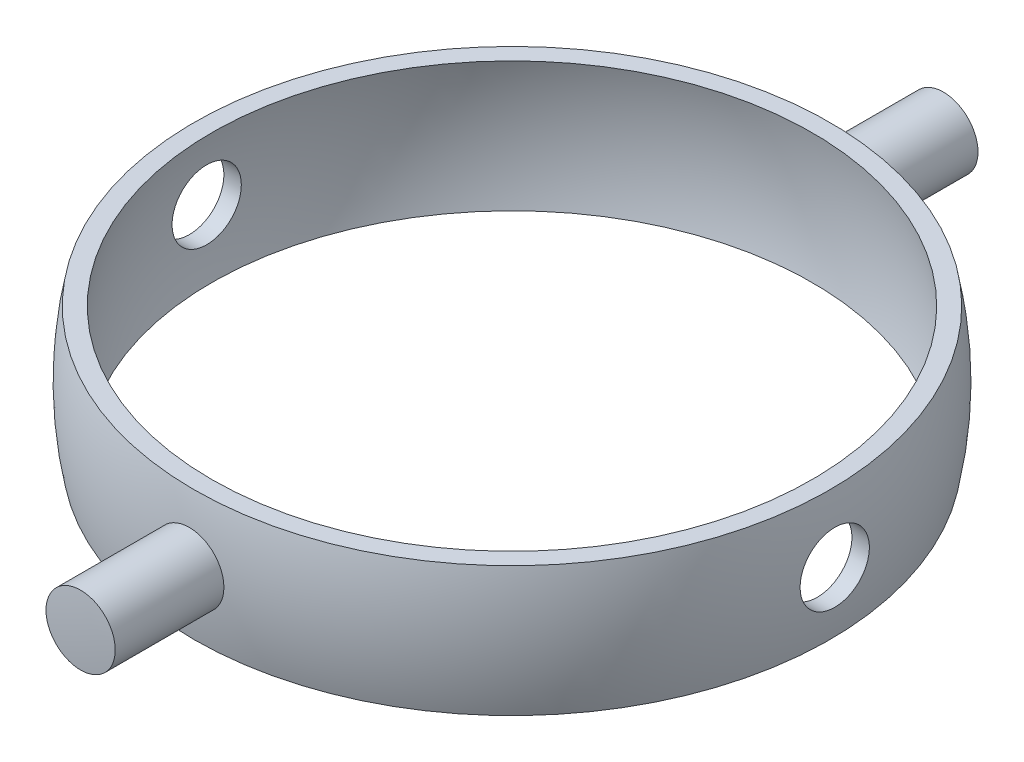
from build123d import *

# Parameters (mm, degrees)
SKETCH2_R               = 4
CUT_EXTRUDE1_DEPTH      = 38.5
CUT_EXTRUDE1_DEPTH_BACK = 38.5
SKETCH3_R               = 4
BOSS_EXTRUDE1_DEPTH     = 12.713944


with BuildPart() as part:
    # Sketch1 → Revolve1 (revolve)
    with BuildSketch(Plane.XY):
        with BuildLine():
            Line((-36.742346142, 7.5), (-34.698703146, 7.5))
            ThreePointArc((-34.698703146, 7.5), (-35.5, 0), (-34.698703146, -7.5))
            Line((-34.698703146, -7.5), (-36.742346142, -7.5))
            ThreePointArc((-36.742346142, -7.5), (-37.5, 0), (-36.742346142, 7.5))
        make_face()
    revolve(axis=Axis((0, 20.373498801, 0), (0, -1, 0)))

    # Sketch2 → Cut-Extrude1 (cut, two sides)
    with BuildSketch(Plane(origin=(0, 0, 0), x_dir=(0, 0, -1), z_dir=(1, 0, 0))) as cut_extrude1_sk:
        Circle(SKETCH2_R)
    extrude(amount=CUT_EXTRUDE1_DEPTH, mode=Mode.SUBTRACT)
    extrude(cut_extrude1_sk.sketch, amount=-CUT_EXTRUDE1_DEPTH_BACK, mode=Mode.SUBTRACT)

    # Sketch3 → Boss-Extrude1 (add)
    with BuildSketch(Plane.XY.offset(50)):
        Circle(SKETCH3_R)
    boss_extrude1 = extrude(amount=-BOSS_EXTRUDE1_DEPTH)

    # Mirror1: Boss-Extrude1 across plane
    add(boss_extrude1.mirror(Plane.XY))

    # Sketch4 → Cut-Revolve1 (revolve, cut)
    with BuildSketch(Plane(origin=(0, 0, 0), x_dir=(0, 0, -1), z_dir=(1, 0, 0))):
        with BuildLine():
            Line((0, -50), (0, -55))
            ThreePointArc((0, -55), (-55, 0), (0, 55))
            Line((0, 55), (0, 50))
            ThreePointArc((0, 50), (-50, 0), (0, -50))
        make_face()
    revolve(axis=Axis((0, 37.66002629, 0), (0, -1, 0)), mode=Mode.SUBTRACT)


solid = part.part
